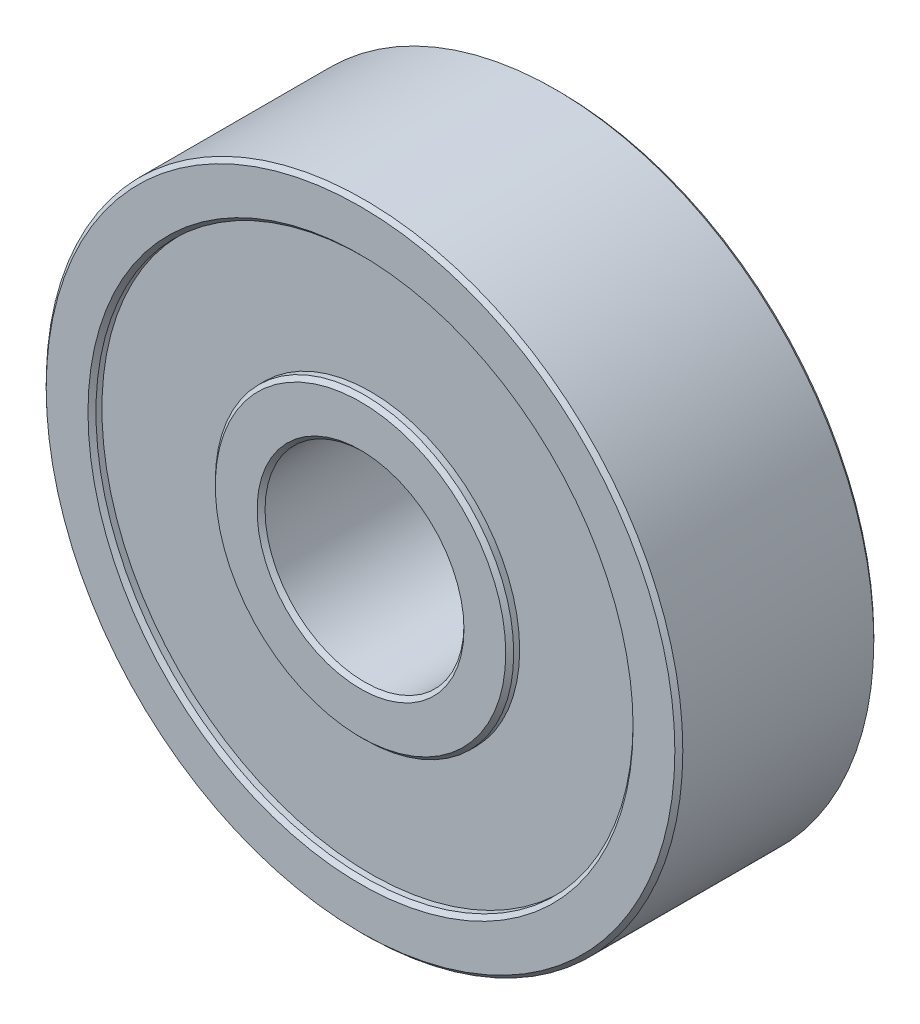
from build123d import *

# Parameters (mm, degrees)
SKETCH1_R                = 8
SKETCH1_R_2              = 2.5
BOSS_EXTRUDE1_DEPTH      = 2.5
BOSS_EXTRUDE1_DEPTH_BACK = 2.5
CUT_EXTRUDE1_START       = -2.5
SKETCH2_R                = 6.75
SKETCH2_R_2              = 3.75
CUT_EXTRUDE1_DEPTH       = 0.25
CUT_EXTRUDE2_START       = 2.5
SKETCH2_2_R              = 6.75
SKETCH2_2_R_2            = 3.75
CUT_EXTRUDE2_DEPTH       = 0.25
CHAMFER1_SIZE            = 0.1


with BuildPart() as part:
    # Sketch1 → Boss-Extrude1 (new body, two sides)
    with BuildSketch(Plane.XY) as boss_extrude1_sk:
        Circle(SKETCH1_R)
        Circle(SKETCH1_R_2, mode=Mode.SUBTRACT)
    extrude(amount=BOSS_EXTRUDE1_DEPTH)
    extrude(boss_extrude1_sk.sketch, amount=-BOSS_EXTRUDE1_DEPTH_BACK)

    # Sketch2 → Cut-Extrude1 (cut)
    with BuildSketch(Plane.XY.offset(CUT_EXTRUDE1_START)):
        Circle(SKETCH2_R)
        Circle(SKETCH2_R_2, mode=Mode.SUBTRACT)
    extrude(amount=CUT_EXTRUDE1_DEPTH, mode=Mode.SUBTRACT)

    # Sketch2_2 → Cut-Extrude2 (cut)
    with BuildSketch(Plane.XY.offset(CUT_EXTRUDE2_START)):
        Circle(SKETCH2_2_R)
        Circle(SKETCH2_2_R_2, mode=Mode.SUBTRACT)
    extrude(amount=-CUT_EXTRUDE2_DEPTH, mode=Mode.SUBTRACT)

    # Chamfer1
    chamfer1_edges = [part.edges().sort_by_distance(p)[0] for p in [
        (-3.75, 0, -2.5),
        (-6.75, 0, -2.5),
        (-6.75, 0, 2.5),
        (-3.75, 0, 2.5),
        (-8, 0, -2.5),
        (-2.5, 0, -2.5),
        (-8, 0, 2.5),
        (-2.5, 0, 2.5),
    ]]
    chamfer(chamfer1_edges, length=CHAMFER1_SIZE)


solid = part.part
